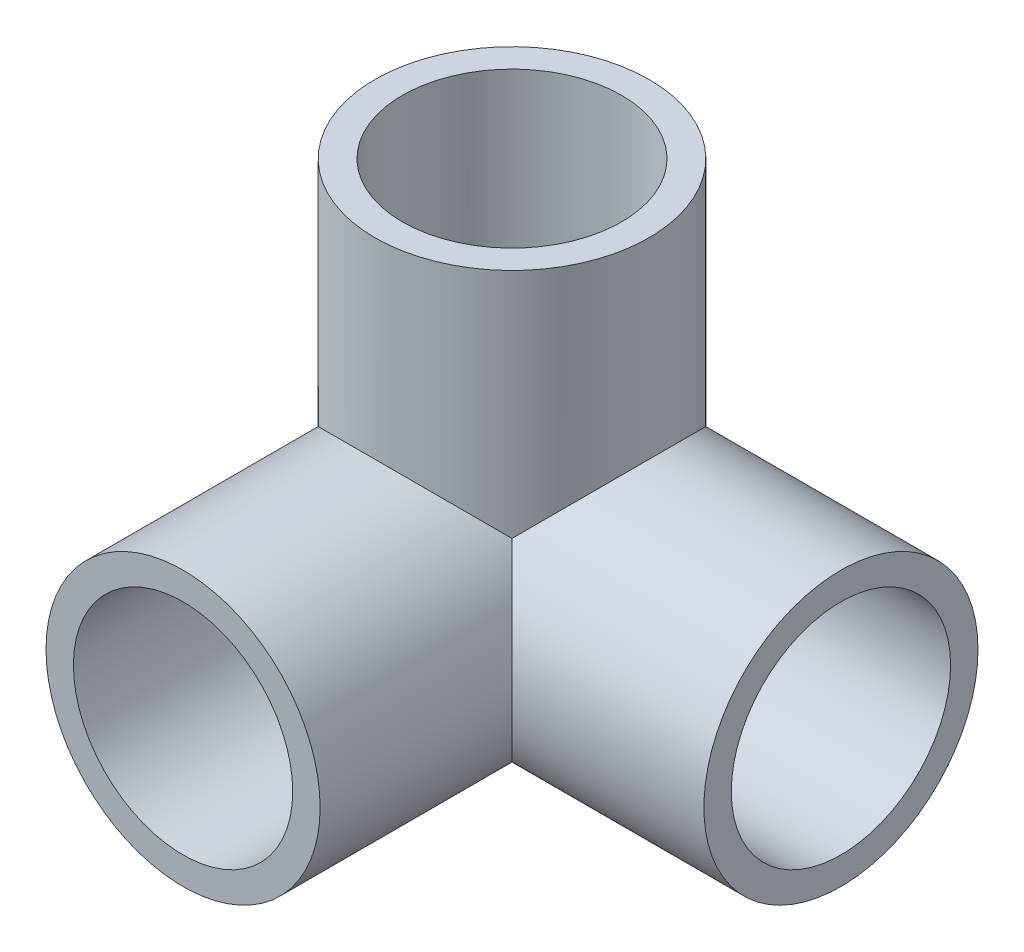
from build123d import *

# Parameters (mm, degrees)
SKETCH1_R           = 15.875
SKETCH1_R_2         = 12.7
BOSS_EXTRUDE1_DEPTH = 38.1
BOSS_EXTRUDE2_DEPTH = 38.1
SKETCH3_R           = 15.875
SKETCH3_R_2         = 12.7
BOSS_EXTRUDE3_DEPTH = 38.1
REVOLVE1_ANGLE      = 90
SKETCH5_R           = 12.7
CUT_EXTRUDE1_DEPTH  = 38.1
SKETCH6_R           = 12.7
CUT_EXTRUDE2_DEPTH  = 38.1
CUT_EXTRUDE3_START  = -38.1
SKETCH7_R           = 12.7
CUT_EXTRUDE3_DEPTH  = 15.875


with BuildPart() as part:
    # Sketch1 → Boss-Extrude1 (new body)
    with BuildSketch(Plane.XY):
        Circle(SKETCH1_R)
        Circle(SKETCH1_R_2, mode=Mode.SUBTRACT)
    extrude(amount=BOSS_EXTRUDE1_DEPTH)

    # Sketch2 → Boss-Extrude2 (add)
    with BuildSketch(Plane(origin=(0, 0, 0), x_dir=(1, 0, 0), z_dir=(0, 1, 0))):
        with BuildLine():
            ThreePointArc((-15.875, 0), (0, -15.875), (15.875, 0))
            Line((15.875, 0), (12.7, 0))
            ThreePointArc((12.7, 0), (0, -12.7), (-12.7, 0))
            Line((-12.7, 0), (-15.875, 0))
        make_face()
        with BuildLine():
            Line((12.7, 0), (15.875, 0))
            ThreePointArc((15.875, 0), (0, 15.875), (-15.875, 0))
            Line((-15.875, 0), (-12.7, 0))
            ThreePointArc((-12.7, 0), (0, 12.7), (12.7, 0))
        make_face()
        with BuildLine():
            ThreePointArc((-15.875, 0), (0, -15.875), (15.875, 0))
            Line((15.875, 0), (12.7, 0))
            ThreePointArc((12.7, 0), (0, -12.7), (-12.7, 0))
            Line((-12.7, 0), (-15.875, 0))
        make_face()
        with BuildLine():
            Line((12.7, 0), (15.875, 0))
            ThreePointArc((15.875, 0), (0, 15.875), (-15.875, 0))
            Line((-15.875, 0), (-12.7, 0))
            ThreePointArc((-12.7, 0), (0, 12.7), (12.7, 0))
        make_face()
    extrude(amount=BOSS_EXTRUDE2_DEPTH)

    # Sketch3 → Boss-Extrude3 (add)
    with BuildSketch(Plane(origin=(0, 0, 0), x_dir=(0, 0, -1), z_dir=(1, 0, 0))):
        Circle(SKETCH3_R)
        Circle(SKETCH3_R_2, mode=Mode.SUBTRACT)
    extrude(amount=BOSS_EXTRUDE3_DEPTH)

    # Sketch4 → Revolve1 (revolve)
    with BuildSketch(Plane.ZY):
        with BuildLine():
            ThreePointArc((-15.875, 0), (-11.225320151, -11.225320151), (0, -15.875))
            Line((0, -15.875), (0, -12.7))
            ThreePointArc((0, -12.7), (-8.980256121, -8.980256121), (-12.7, 0))
            Line((-12.7, 0), (-15.875, 0))
        make_face()
    revolve(axis=Axis((0, 0, -12.7), (0, 0, -1)), revolution_arc=REVOLVE1_ANGLE)

    # Sketch5 → Cut-Extrude1 (cut)
    with BuildSketch(Plane(origin=(0, 38.1, 0), x_dir=(1, 0, 0), z_dir=(0, 1, 0))):
        Circle(SKETCH5_R)
    extrude(amount=-CUT_EXTRUDE1_DEPTH, mode=Mode.SUBTRACT)

    # Sketch6 → Cut-Extrude2 (cut)
    with BuildSketch(Plane.XY.offset(38.1)):
        Circle(SKETCH6_R)
    extrude(amount=-CUT_EXTRUDE2_DEPTH, mode=Mode.SUBTRACT)

    # Sketch7 → Cut-Extrude3 (cut)
    with BuildSketch(Plane(origin=(38.1, 0, 0), x_dir=(0, 0, -1), z_dir=(1, 0, 0)).offset(CUT_EXTRUDE3_START)):
        Circle(SKETCH7_R)
    extrude(amount=CUT_EXTRUDE3_DEPTH, mode=Mode.SUBTRACT)


solid = part.part
